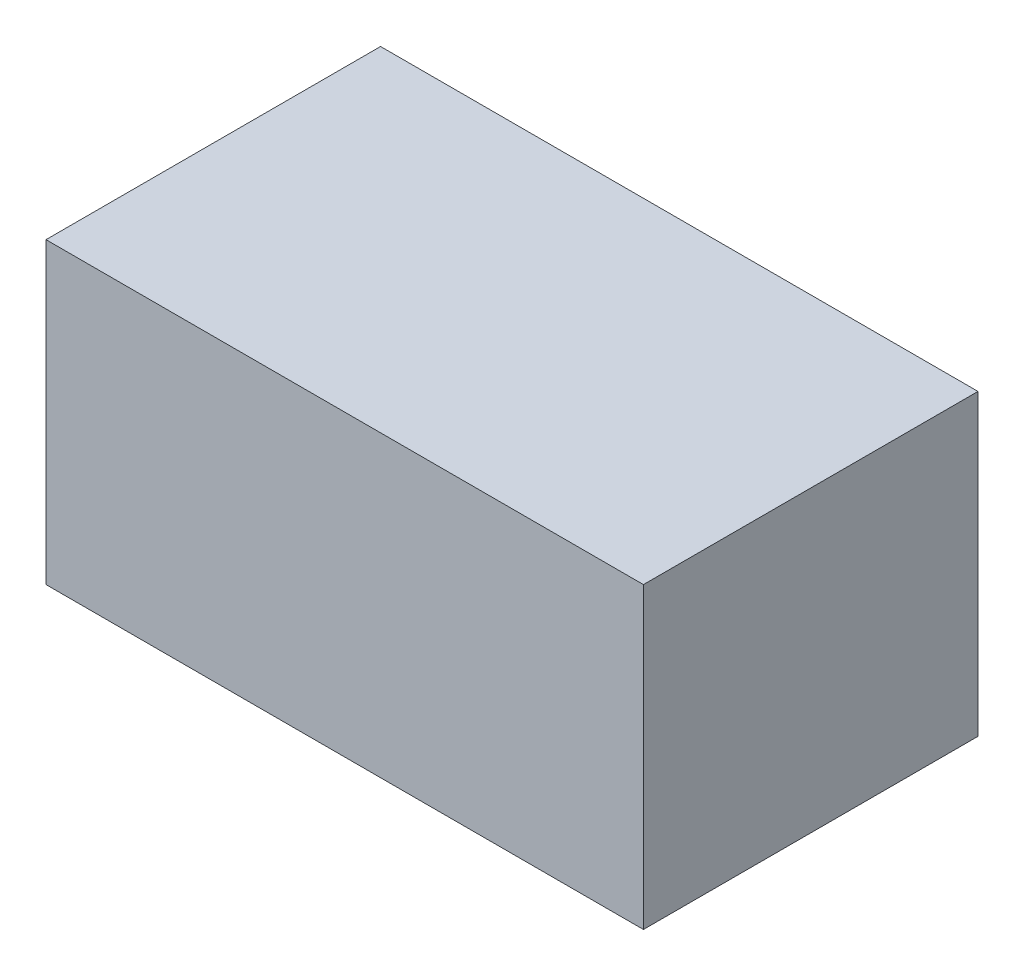
from build123d import *

# Parameters (mm, degrees)
SKETCH1_W           = 50
SKETCH1_H           = 25
BOSS_EXTRUDE1_DEPTH = 28


with BuildPart() as part:
    # Sketch1 → Boss-Extrude1 (new body)
    with BuildSketch(Plane.XY):
        with Locations((25, -12.5)):
            Rectangle(SKETCH1_W, SKETCH1_H)
    extrude(amount=BOSS_EXTRUDE1_DEPTH)


solid = part.part
